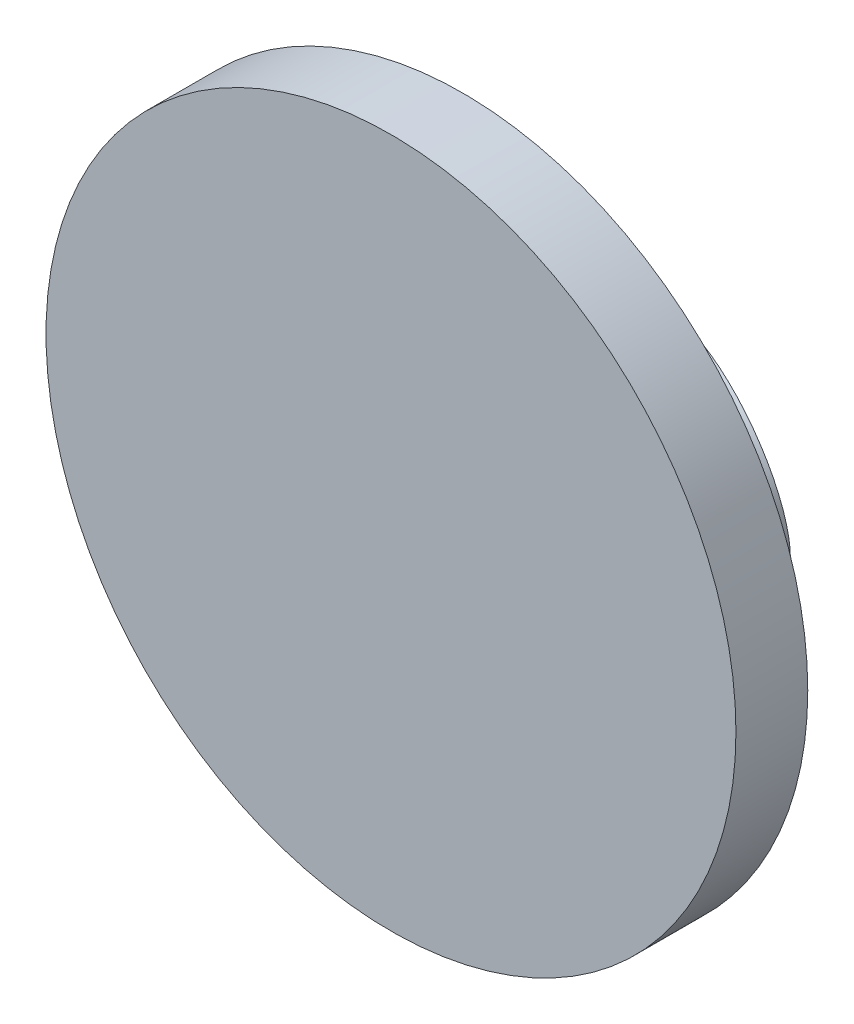
from build123d import *

# Parameters (mm, degrees)
SKETCH1_R           = 42.5
BOSS_EXTRUDE1_DEPTH = 8.85
BOSS_EXTRUDE2_START = -10
SKETCH6_R           = 13.155696691
BOSS_EXTRUDE2_DEPTH = 10
CIRPATTERN1_COUNT   = 3


with BuildPart() as part:
    # Sketch1 → Boss-Extrude1 (new body)
    with BuildSketch(Plane.XY):
        Circle(SKETCH1_R)
    extrude(amount=BOSS_EXTRUDE1_DEPTH)

    # Sketch6 → Boss-Extrude2 (add)
    with BuildSketch(Plane(origin=(0, 1.664252335, 4.57249571), x_dir=(-1, 0, 0), z_dir=(-2.371601618479234e-15, 0.34202014332567576, 0.9396926207859059)).offset(BOSS_EXTRUDE2_START)):
        with Locations((0, 26.738166151)):
            Circle(SKETCH6_R)
    boss_extrude2 = extrude(amount=-BOSS_EXTRUDE2_DEPTH)

    # CirPattern1: Boss-Extrude2 ×3 about axis
    cirpattern1_axis = Axis((0, 0, 8.85), (0, 0, -1))
    for i in range(1, CIRPATTERN1_COUNT):
        add(boss_extrude2.rotate(cirpattern1_axis, i * 360 / CIRPATTERN1_COUNT))


solid = part.part
